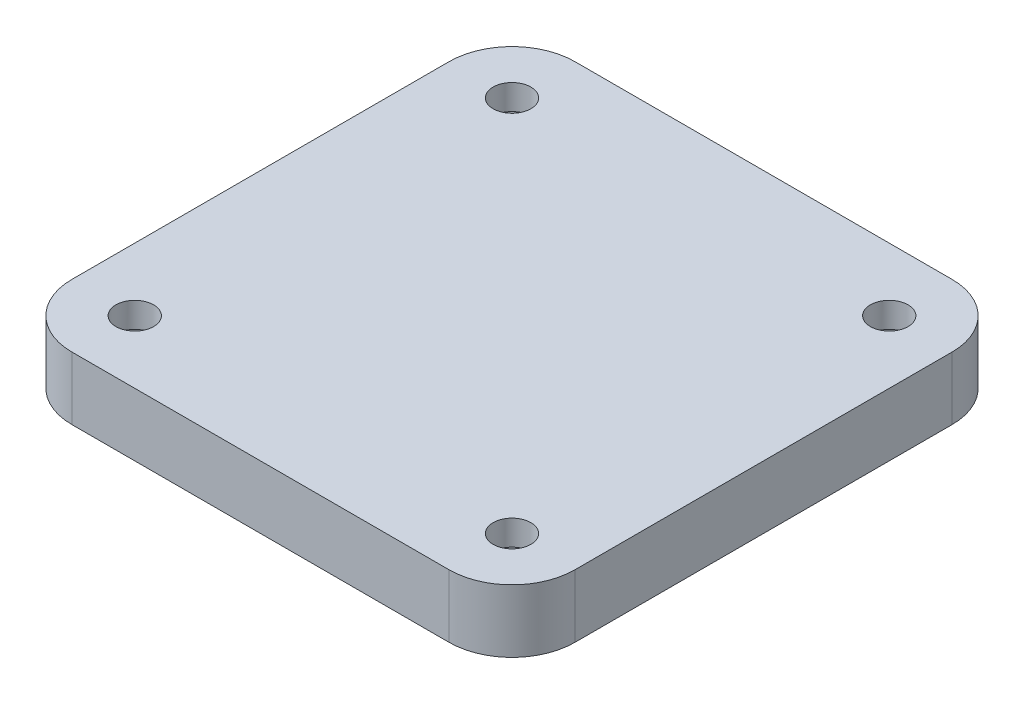
from build123d import *

# Parameters (mm, degrees)
SKETCH_1_W          = 40
SKETCH_1_H          = 40
EXTRUDE_1_DEPTH     = 5
SKETCH_2_R          = 1.5
CUT_EXTRUDE_1_DEPTH = 10
FILLET_1_R          = 5
CUT_EXTRUDE_3_DEPTH = 3


with BuildPart() as part:
    # 草图1 → 凸台-拉伸1 (new body)
    with BuildSketch(Plane(origin=(0, 0, 0), x_dir=(1, 0, 0), z_dir=(0, 1, 0))):
        Rectangle(SKETCH_1_W, SKETCH_1_H)
    extrude(amount=EXTRUDE_1_DEPTH)

    # 草图2 → 切除-拉伸1 (cut)
    with BuildSketch(Plane(origin=(0, 5, 0), x_dir=(1, 0, 0), z_dir=(0, 1, 0))):
        with Locations((-15, 15)):
            Circle(SKETCH_2_R)
        with Locations((15, 15)):
            Circle(SKETCH_2_R)
        with Locations((15, -15)):
            Circle(SKETCH_2_R)
        with Locations((-15, -15)):
            Circle(SKETCH_2_R)
    extrude(amount=-CUT_EXTRUDE_1_DEPTH, mode=Mode.SUBTRACT)

    # 圆角1
    fillet_1_edges = [part.edges().sort_by_distance(p)[0] for p in [
        (20, 2.5, 20),
        (-20, 2.5, 20),
        (-20, 2.5, -20),
        (20, 2.5, -20),
    ]]
    fillet(fillet_1_edges, radius=FILLET_1_R)

    # 草图4 → 切除-拉伸3 (cut)
    with BuildSketch(Plane.XZ):
        Polygon((12.25, 16.58771324), (15, 18.175426481), (17.75, 16.58771324), (17.75, 13.41228676), (15, 11.824573519), (12.25, 13.41228676), align=None)
        Polygon((-15, 18.175426481), (-17.75, 16.58771324), (-17.75, 13.41228676), (-15, 11.824573519), (-12.25, 13.41228676), (-12.25, 16.58771324), align=None)
        Polygon((12.25, -13.41228676), (12.25, -16.58771324), (15, -18.175426481), (17.75, -16.58771324), (17.75, -13.41228676), (15, -11.824573519), align=None)
        Polygon((-12.25, -16.58771324), (-15, -18.175426481), (-17.75, -16.58771324), (-17.75, -13.41228676), (-15, -11.824573519), (-12.25, -13.41228676), align=None)
    extrude(amount=-CUT_EXTRUDE_3_DEPTH, mode=Mode.SUBTRACT)


solid = part.part
